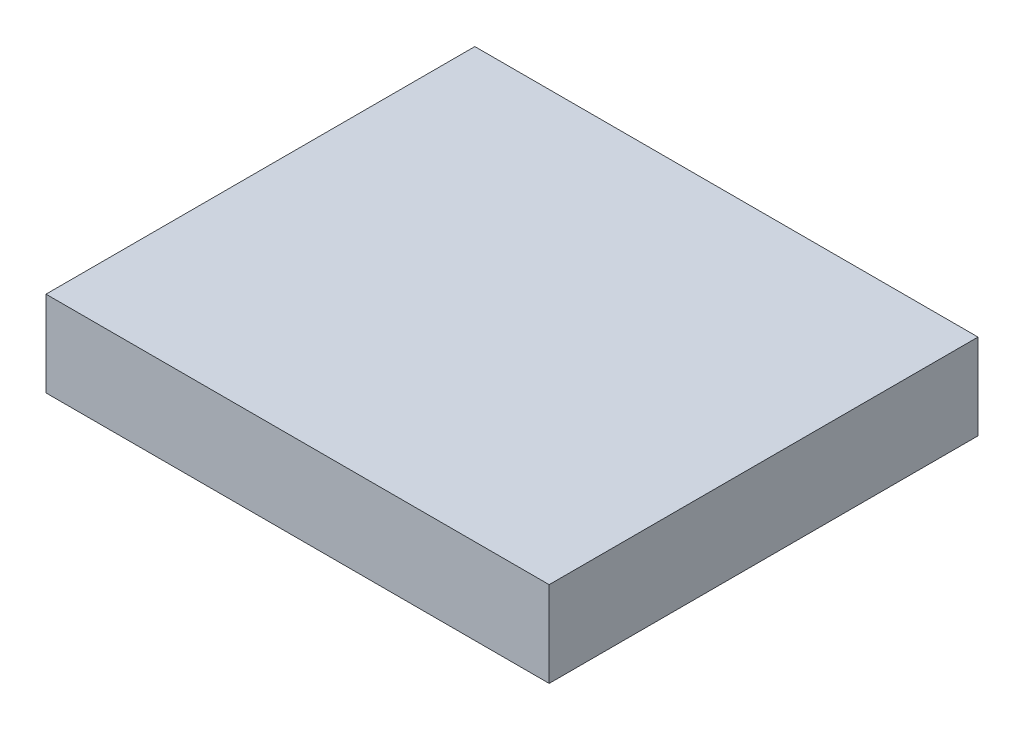
from build123d import *

# Parameters (mm, degrees)
CROQUIS1_W              = 58.803715618
CROQUIS1_H              = 50.117543921
SALIENTE_EXTRUIR1_DEPTH = 10


with BuildPart() as part:
    # Croquis1 → Saliente-Extruir1 (new body)
    with BuildSketch(Plane(origin=(0, 0, 0), x_dir=(1, 0, 0), z_dir=(0, 1, 0))):
        with Locations((29.401857809, 25.058771961)):
            Rectangle(CROQUIS1_W, CROQUIS1_H)
    extrude(amount=SALIENTE_EXTRUIR1_DEPTH)


solid = part.part
